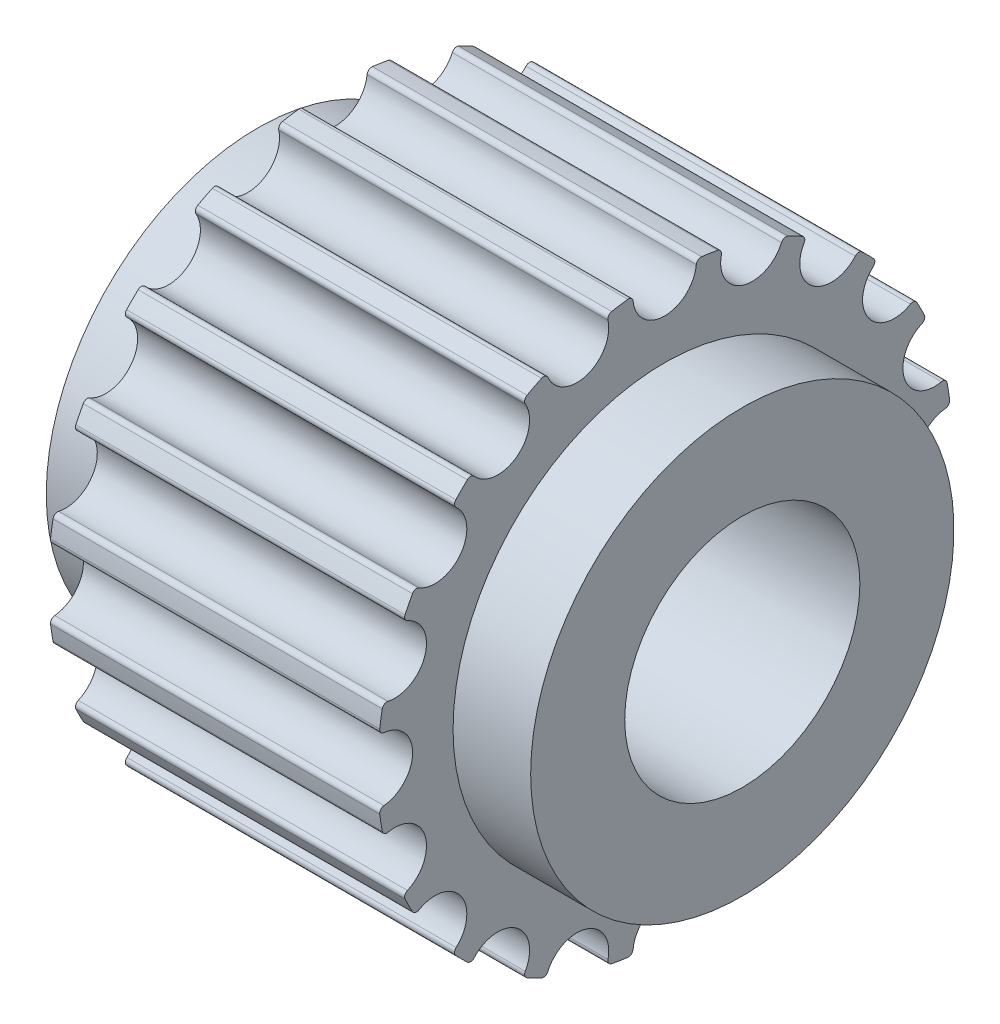
from build123d import *

# Parameters (mm, degrees)
CUT_EXTRUDE1_DEPTH       = 9.65
FILLET1_R                = 0.1
CIRPATTERN1_COUNT        = 20
FILLET1_OF_CIRPATTERN1_R = 0.1


with BuildPart() as part:
    # Sketch1 → Revolve1 (revolve)
    with BuildSketch(Plane.XY):
        Polygon((1.65, 6.11), (8.65, 6.11), (8.65, 4.5), (10.3, 4.5), (10.3, 2.5), (0, 2.5), (0, 4.5), (1.65, 4.5), align=None)
    revolve(axis=Axis((0, 0, 0), (1, 0, 0)))

    # Sketch2 → Cut-Extrude1 (cut, through all)
    with BuildSketch(Plane(origin=(1.65, 0, 0), x_dir=(0, 0, -1), z_dir=(1, 0, 0))):
        with BuildLine():
            ThreePointArc((0.673945392, 6.072717481), (0, 6.11), (-0.673945392, 6.072717481))
            ThreePointArc((-0.673945392, 6.072717481), (0, 5.36), (0.673945392, 6.072717481))
        make_face()
    cut_extrude1 = extrude(amount=CUT_EXTRUDE1_DEPTH, mode=Mode.SUBTRACT)

    # Fillet1
    fillet1_edges = [part.edges().sort_by_distance(p)[0] for p in [
        (5.15, 6.072717481, 0.673945392),
        (5.15, 6.072717481, -0.673945392),
    ]]
    fillet(fillet1_edges, radius=FILLET1_R)

    # CirPattern1: Cut-Extrude1 ×20 about axis
    cirpattern1_axis = Axis((0, 0, 0), (1, 0, 0))
    for i in range(1, CIRPATTERN1_COUNT):
        add(cut_extrude1.rotate(cirpattern1_axis, i * 360 / CIRPATTERN1_COUNT), mode=Mode.SUBTRACT)

    # Fillet1 of CirPattern1
    fillet1_of_cirpattern1_edges = [part.edges().sort_by_distance(p)[0] for p in [
        (5.15, 5.567236953, 2.517533061),
        (5.15, 5.983758112, 1.235612747),
        (5.15, 4.516796482, 4.114687052),
        (5.15, 5.309066807, 3.024220501),
        (5.15, 3.024220501, 5.309066807),
        (5.15, 4.114687052, 4.516796482),
        (5.15, 1.235612747, 5.983758112),
        (5.15, 2.517533061, 5.567236953),
        (5.15, -0.673945392, 6.072717481),
        (5.15, 0.673945392, 6.072717481),
        (5.15, -2.517533061, 5.567236953),
        (5.15, -1.235612747, 5.983758112),
        (5.15, -4.114687052, 4.516796482),
        (5.15, -3.024220501, 5.309066807),
        (5.15, -5.309066807, 3.024220501),
        (5.15, -4.516796482, 4.114687052),
        (5.15, -5.983758112, 1.235612747),
        (5.15, -5.567236953, 2.517533061),
        (5.15, -6.072717481, -0.673945392),
        (5.15, -6.072717481, 0.673945392),
        (5.15, -5.567236953, -2.517533061),
        (5.15, -5.983758112, -1.235612747),
        (5.15, -4.516796482, -4.114687052),
        (5.15, -5.309066807, -3.024220501),
        (5.15, -3.024220501, -5.309066807),
        (5.15, -4.114687052, -4.516796482),
        (5.15, -1.235612747, -5.983758112),
        (5.15, -2.517533061, -5.567236953),
        (5.15, 0.673945392, -6.072717481),
        (5.15, -0.673945392, -6.072717481),
        (5.15, 2.517533061, -5.567236953),
        (5.15, 1.235612747, -5.983758112),
        (5.15, 4.114687052, -4.516796482),
        (5.15, 3.024220501, -5.309066807),
        (5.15, 5.309066807, -3.024220501),
        (5.15, 4.516796482, -4.114687052),
        (5.15, 5.983758112, -1.235612747),
        (5.15, 5.567236953, -2.517533061),
    ]]
    fillet(fillet1_of_cirpattern1_edges, radius=FILLET1_OF_CIRPATTERN1_R)


solid = part.part
